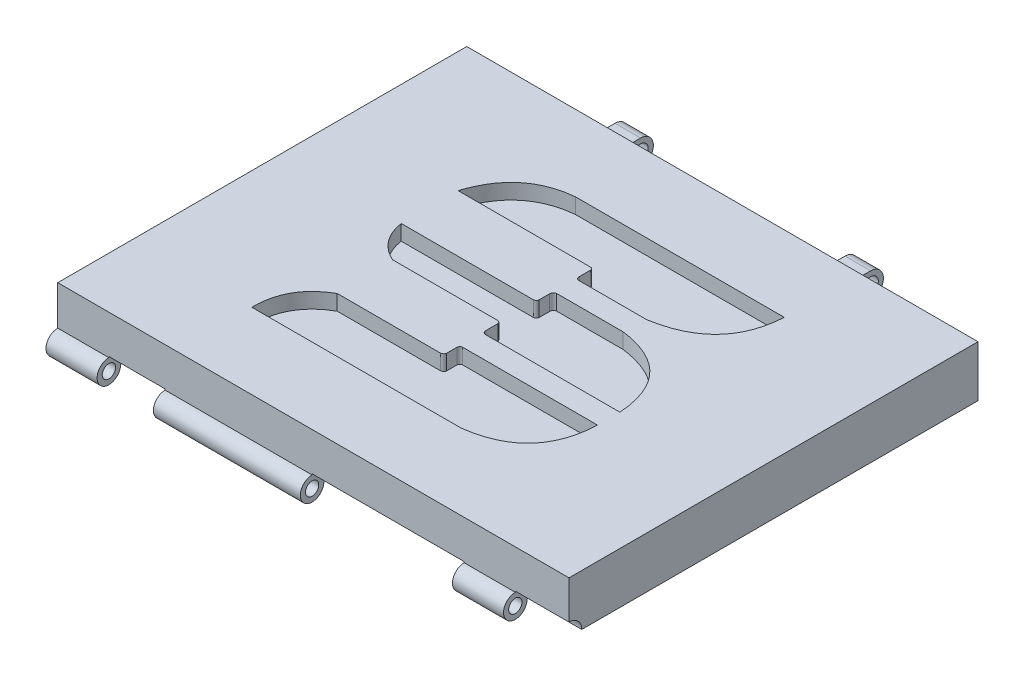
from build123d import *

# Parameters (mm, degrees)
SKETCH1_W            = 254
SKETCH1_H            = 203.2
BOSS_EXTRUDE2_DEPTH  = 12.7
SKETCH2_W            = 254
SKETCH2_H            = 203.2
SKETCH2_W_2          = 228.6
SKETCH2_H_2          = 177.8
BOSS_EXTRUDE3_DEPTH  = 12.7
SKETCH6_R            = 6.35
CUT_EXTRUDE2_DEPTH   = 52.07
SKETCH8_R            = 6.35
CUT_EXTRUDE3_DEPTH   = 52.07
SKETCH9_R            = 3.302
BOSS_EXTRUDE5_DEPTH  = 25.4
SKETCH10_R           = 6.35
CUT_EXTRUDE4_DEPTH   = 45.212
SKETCH11_R           = 6.35
CUT_EXTRUDE5_DEPTH   = 190.246
SKETCH12_R           = 5.842
SKETCH12_R_2         = 3.302
BOSS_EXTRUDE6_DEPTH  = 24.13
SKETCH15_R           = 6.35
CUT_EXTRUDE6_DEPTH   = 1.27
SKETCH17_R           = 3.302
BOSS_EXTRUDE7_DEPTH  = 1.27
SKETCH18_R           = 3.302
BOSS_EXTRUDE8_DEPTH  = 1.27
SKETCH19_R           = 5.842
SKETCH19_R_2         = 3.302
BOSS_EXTRUDE9_DEPTH  = 73.025
CUT_EXTRUDE7_DEPTH   = 7.62
SKETCH21_R           = 6.35
BOSS_EXTRUDE10_DEPTH = 12.7
SKETCH23_R           = 6.35
BOSS_EXTRUDE11_DEPTH = 12.7
SKETCH24_R           = 3.81
CUT_EXTRUDE8_DEPTH   = 167.132
FILLET1_R            = 5.08


with BuildPart() as part:
    # Sketch1 → Boss-Extrude2 (new body)
    with BuildSketch(Plane(origin=(0, 0, 0), x_dir=(1, 0, 0), z_dir=(0, 1, 0))):
        with Locations((127, 101.6)):
            Rectangle(SKETCH1_W, SKETCH1_H)
    extrude(amount=BOSS_EXTRUDE2_DEPTH)

    # Sketch2 → Boss-Extrude3 (add)
    with BuildSketch(Plane(origin=(0, 0, 0), x_dir=(-1, 0, 0), z_dir=(0, -1, 0))):
        with Locations((-127, 101.6)):
            Rectangle(SKETCH2_W, SKETCH2_H)
        with Locations((-127, 101.6)):
            Rectangle(SKETCH2_W_2, SKETCH2_H_2, mode=Mode.SUBTRACT)
    extrude(amount=BOSS_EXTRUDE3_DEPTH)

    # Sketch6 → Cut-Extrude2 (cut)
    with BuildSketch(Plane(origin=(228.6, 0, 0), x_dir=(0, 0, -1), z_dir=(1, 0, 0))):
        with Locations((0, -12.7)):
            Circle(SKETCH6_R)
    extrude(amount=-CUT_EXTRUDE2_DEPTH, mode=Mode.SUBTRACT)

    # Sketch8 → Cut-Extrude3 (cut)
    with BuildSketch(Plane.ZY.offset(-25.4)):
        with Locations((0, -12.7)):
            Circle(SKETCH8_R)
    extrude(amount=-CUT_EXTRUDE3_DEPTH, mode=Mode.SUBTRACT)

    # Sketch9 → Boss-Extrude5 (add)
    with BuildSketch(Plane(origin=(228.6, 0, 0), x_dir=(0, 0, -1), z_dir=(1, 0, 0))):
        with BuildLine():
            Line((0, -4.734153711), (0, -6.858))
            ThreePointArc((0, -6.858), (-4.130917816, -16.830917816), (5.842, -12.7))
            Line((5.842, -12.7), (6.842694324, -12.7))
            Line((6.842694324, -12.7), (6.842694324, -8.927228158))
            Line((6.842694324, -8.927228158), (0, -4.734153711))
        make_face()
        with Locations((0, -12.7)):
            Circle(SKETCH9_R, mode=Mode.SUBTRACT)
    extrude(amount=-BOSS_EXTRUDE5_DEPTH)

    # Sketch10 → Cut-Extrude4 (cut)
    with BuildSketch(Plane(origin=(228.6, 0, 0), x_dir=(0, 0, -1), z_dir=(1, 0, 0))):
        with Locations((0, -12.7)):
            Circle(SKETCH10_R)
    extrude(amount=CUT_EXTRUDE4_DEPTH, mode=Mode.SUBTRACT)

    # Sketch11 → Cut-Extrude5 (cut)
    with BuildSketch(Plane(origin=(176.53, 0, 0), x_dir=(0, 0, -1), z_dir=(1, 0, 0))):
        with Locations((0, -12.7)):
            Circle(SKETCH11_R)
    extrude(amount=-CUT_EXTRUDE5_DEPTH, mode=Mode.SUBTRACT)

    # Sketch12 → Boss-Extrude6 (add)
    with BuildSketch(Plane.ZY):
        with BuildLine():
            ThreePointArc((-5.842, -12.7), (-4.130917816, -8.569082184), (0, -6.858))
            Line((0, -6.858), (0, -6.35))
            ThreePointArc((0, -6.35), (-4.490128061, -8.209871939), (-6.35, -12.7))
            Line((-6.35, -12.7), (-5.842, -12.7))
        make_face()
        with Locations((0, -12.7)):
            Circle(SKETCH12_R)
        with Locations((0, -12.7)):
            Circle(SKETCH12_R_2, mode=Mode.SUBTRACT)
    extrude(amount=-BOSS_EXTRUDE6_DEPTH)

    # Sketch15 → Cut-Extrude6 (cut)
    with BuildSketch(Plane(origin=(228.6, 0, 0), x_dir=(0, 0, -1), z_dir=(1, 0, 0))):
        with Locations((0, -12.7)):
            Circle(SKETCH15_R)
    extrude(amount=-CUT_EXTRUDE6_DEPTH, mode=Mode.SUBTRACT)

    # Sketch17 → Boss-Extrude7 (add)
    with BuildSketch(Plane.ZY.offset(-203.2)):
        with BuildLine():
            ThreePointArc((-5.842, -12.7), (-4.130917816, -8.569082184), (0, -6.858))
            Line((0, -6.858), (0, -6.35))
            ThreePointArc((0, -6.35), (-4.490128061, -8.209871939), (-6.35, -12.7))
            Line((-6.35, -12.7), (-5.842, -12.7))
        make_face()
        with BuildLine():
            ThreePointArc((5.842, -12.7), (4.130917816, -8.569082184), (0, -6.858))
            ThreePointArc((0, -6.858), (-4.130917816, -8.569082184), (-5.842, -12.7))
            ThreePointArc((-5.842, -12.7), (0, -18.542), (5.842, -12.7))
        make_face()
        with Locations((0, -12.7)):
            Circle(SKETCH17_R, mode=Mode.SUBTRACT)
    extrude(amount=BOSS_EXTRUDE7_DEPTH)

    # Sketch18 → Boss-Extrude8 (add)
    with BuildSketch(Plane(origin=(24.13, 0, 0), x_dir=(0, 0, -1), z_dir=(1, 0, 0))):
        with BuildLine():
            Line((0, -6.35), (0, -6.858))
            ThreePointArc((0, -6.858), (4.130917816, -8.569082184), (5.842, -12.7))
            Line((5.842, -12.7), (6.35, -12.7))
            ThreePointArc((6.35, -12.7), (4.490128061, -8.209871939), (0, -6.35))
        make_face()
        with BuildLine():
            ThreePointArc((5.842, -12.7), (4.130917816, -8.569082184), (0, -6.858))
            ThreePointArc((0, -6.858), (-4.130917816, -16.830917816), (5.842, -12.7))
        make_face()
        with Locations((0, -12.7)):
            Circle(SKETCH18_R, mode=Mode.SUBTRACT)
    extrude(amount=BOSS_EXTRUDE8_DEPTH)

    # Sketch19 → Boss-Extrude9 (add)
    with BuildSketch(Plane.ZY.offset(-53.34)):
        with BuildLine():
            ThreePointArc((-5.842, -12.7), (-4.130917816, -8.569082184), (0, -6.858))
            Line((0, -6.858), (0, -5.334694101))
            Line((0, -5.334694101), (-5.217733662, -7.625492191))
            Line((-5.217733662, -7.625492191), (-6.523890468, -10.619605484))
            Line((-6.523890468, -10.619605484), (-6.724837669, -12.7))
            Line((-6.724837669, -12.7), (-5.842, -12.7))
        make_face()
        with Locations((0, -12.7)):
            Circle(SKETCH19_R)
        with Locations((0, -12.7)):
            Circle(SKETCH19_R_2, mode=Mode.SUBTRACT)
    extrude(amount=-BOSS_EXTRUDE9_DEPTH)

    # Sketch3 → Cut-Extrude7 (cut)
    with BuildSketch(Plane(origin=(0, 12.7, 0), x_dir=(1, 0, 0), z_dir=(0, 1, 0))):
        with BuildLine():
            Line((195.366950221, 165.545782342), (91.71222682, 165.545782342))
            add(Edge.make_bspline(
                [(91.71222682, 165.545782342), (67.539208551, 163.235170178), (59.846395191, 139.038085668)],
                knots=[0, 0, 0, 1, 1, 1], degree=2))
            Line((59.846395191, 139.038085668), (125.30712104, 139.038085668))
            add(Edge.make_bspline(
                [(125.30712104, 139.038085668), (126.780616205, 139.122377702), (126.96048329, 137.769188416)],
                knots=[0, 0, 0, 1, 1, 1], degree=2))
            Line((126.96048329, 137.769188416), (126.96048329, 132.272484091))
            add(Edge.make_bspline(
                [(126.96048329, 132.272484091), (126.876874172, 130.733531241), (128.303731924, 130.371199046)],
                knots=[0, 0, 0, 1, 1, 1], degree=2))
            Line((128.303731924, 130.371199046), (162.187188306, 130.371199046))
            add(Edge.make_bspline(
                [(195.366950221, 165.545782342), (193.745607246, 135.56730888), (162.187188306, 130.371199046)],
                knots=[0, 0, 0, 1, 1, 1], degree=2))
        make_face()
        with BuildLine():
            Line((161.642347888, 119.295964928), (128.497808789, 119.295964928))
            add(Edge.make_bspline(
                [(128.497808789, 119.295964928), (127.070096751, 118.926569019), (126.96048329, 117.397764841)],
                knots=[0, 0, 0, 1, 1, 1], degree=2))
            Line((126.96048329, 117.397764841), (126.96048329, 112.151116085))
            add(Edge.make_bspline(
                [(126.96048329, 112.151116085), (126.743790117, 110.899444942), (125.464733978, 110.784690654)],
                knots=[0, 0, 0, 1, 1, 1], degree=2))
            Line((125.464733978, 110.784690654), (59.846395191, 110.784690654))
            add(Edge.make_bspline(
                [(59.846395191, 110.784690654), (61.887337052, 98.301496186), (73.317351169, 93.027012339)],
                knots=[0, 0, 0, 1, 1, 1], degree=2))
            Line((73.317351169, 93.027012339), (125.464733978, 93.027012339))
            add(Edge.make_bspline(
                [(125.464733978, 93.027012339), (126.711731964, 92.919963041), (126.96048329, 91.748824412)],
                knots=[0, 0, 0, 1, 1, 1], degree=2))
            Line((126.96048329, 91.748824412), (126.96048329, 85.74475013))
            add(Edge.make_bspline(
                [(126.96048329, 85.74475013), (127.024328685, 84.195885842), (128.497808789, 83.912442397)],
                knots=[0, 0, 0, 1, 1, 1], degree=2))
            Line((128.497808789, 83.912442397), (195.366950221, 83.912442397))
            add(Edge.make_bspline(
                [(161.642347888, 119.295964928), (193.222633695, 115.013388161), (195.366950221, 83.912442397)],
                knots=[0, 0, 0, 1, 1, 1], degree=2))
        make_face()
        with BuildLine():
            Line((195.366950221, 72.802355269), (128.303731924, 72.802355269))
            add(Edge.make_bspline(
                [(128.303731924, 72.802355269), (127.014045367, 72.648063165), (126.96048329, 71.297279055)],
                knots=[0, 0, 0, 1, 1, 1], degree=2))
            Line((126.96048329, 71.297279055), (126.96048329, 66.07466352))
            add(Edge.make_bspline(
                [(126.96048329, 66.07466352), (126.573968469, 64.92692802), (125.30712104, 64.769219048)],
                knots=[0, 0, 0, 1, 1, 1], degree=2))
            Line((125.30712104, 64.769219048), (74.082862231, 64.769219048))
            add(Edge.make_bspline(
                [(74.082862231, 64.769219048), (58.4794695, 55.884745917), (58.811181594, 37.622601841)],
                knots=[0, 0, 0, 1, 1, 1], degree=2))
            Line((58.811181594, 37.622601841), (162.716666362, 37.622601841))
            add(Edge.make_bspline(
                [(162.716666362, 37.622601841), (194.140729717, 41.705995139), (195.366950221, 72.802355269)],
                knots=[0, 0, 0, 1, 1, 1], degree=2))
        make_face()
    extrude(amount=-CUT_EXTRUDE7_DEPTH, mode=Mode.SUBTRACT)

    # Sketch21 → Boss-Extrude10 (add)
    with BuildSketch(Plane(origin=(177.8, 0, 0), x_dir=(0, 0, -1), z_dir=(1, 0, 0))):
        with BuildLine():
            Line((203.2, 6.35), (203.2, 0))
            Line((203.2, 0), (203.2, -6.35))
            Line((203.2, -6.35), (213.36, -6.35))
            ThreePointArc((213.36, -6.35), (207.01, 0), (213.36, 6.35))
            Line((213.36, 6.35), (203.2, 6.35))
        make_face()
        with Locations((213.36, 0)):
            Circle(SKETCH21_R)
    extrude(amount=BOSS_EXTRUDE10_DEPTH)

    # Sketch23 → Boss-Extrude11 (add)
    with BuildSketch(Plane(origin=(76.2, 0, 0), x_dir=(0, 0, -1), z_dir=(1, 0, 0))):
        with BuildLine():
            Line((213.36, 6.35), (203.2, 6.35))
            Line((203.2, 6.35), (203.2, -6.35))
            Line((203.2, -6.35), (213.36, -6.35))
            ThreePointArc((213.36, -6.35), (207.01, 0), (213.36, 6.35))
        make_face()
        with Locations((213.36, 0)):
            Circle(SKETCH23_R)
    extrude(amount=-BOSS_EXTRUDE11_DEPTH)

    # Sketch24 → Cut-Extrude8 (cut)
    with BuildSketch(Plane.ZY.offset(-63.5)):
        with Locations((-213.36, 0)):
            Circle(SKETCH24_R)
    extrude(amount=-CUT_EXTRUDE8_DEPTH, mode=Mode.SUBTRACT)

    # Fillet1
    fillet1_edges = [part.edges().sort_by_distance(p)[0] for p in [
        (184.15, -6.35, -203.2),
        (184.15, 6.35, -203.2),
        (69.85, -6.35, -203.2),
        (69.85, 6.35, -203.2),
    ]]
    fillet(fillet1_edges, radius=FILLET1_R)


solid = part.part
